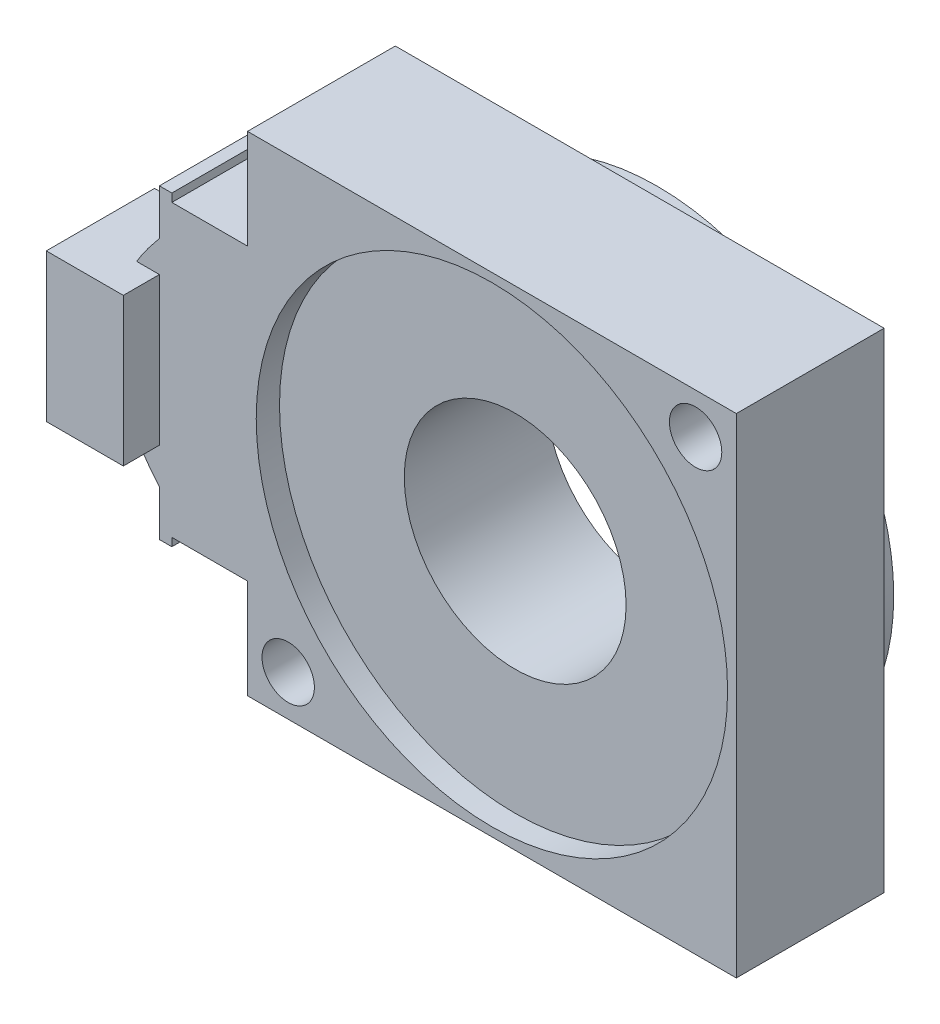
from build123d import *

# Parameters (mm, degrees)
BOSS_EXTRUDE1_DEPTH      = 12.7
SKETCH2_R                = 2.25
CUT_EXTRUDE1_DEPTH       = 12.7
BOSS_EXTRUDE4_DEPTH      = 12.7
SKETCH4_R                = 20.25
CUT_EXTRUDE2_DEPTH       = 2
SKETCH6_R                = 20.325
BOSS_EXTRUDE5_DEPTH      = 1.5
SKETCH5_R                = 9.53
CUT_EXTRUDE3_DEPTH       = 30
SKETCH8_W                = 6.62
SKETCH8_H                = 12.7
BOSS_EXTRUDE7_DEPTH      = 3.1
BOSS_EXTRUDE7_DEPTH_BACK = 6.2


with BuildPart() as part:
    # Sketch1 → Boss-Extrude1 (new body)
    with BuildSketch(Plane.XY):
        Polygon((0, 21), (21, 21), (21, -21), (-21, -21), (-21, 21), align=None)
    extrude(amount=BOSS_EXTRUDE1_DEPTH)

    # Sketch2 → Cut-Extrude1 (cut)
    with BuildSketch(Plane.XY):
        with Locations((17.500892834, 17.500892834)):
            Circle(SKETCH2_R)
        with Locations((-17.500892834, -17.500892834)):
            Circle(SKETCH2_R)
    extrude(amount=CUT_EXTRUDE1_DEPTH, mode=Mode.SUBTRACT)

    # Sketch3 → Boss-Extrude4 (add)
    with BuildSketch(Plane.XY.offset(12.7)):
        with BuildLine():
            Line((-21, -12.460892834), (-27.5, -12.460892834))
            Line((-27.5, -12.460892834), (-27.5, -13.160892834))
            Line((-27.5, -13.160892834), (-28.57, -13.160892834))
            Line((-28.57, -13.160892834), (-28.57, -9.240892834))
            add(Edge.make_bspline(
                [(-28.57, 9.240892834), (-36.45, 0), (-28.57, -9.240892834)],
                knots=[0, 0, 0, 1, 1, 1], degree=2))
            Line((-28.57, 9.240892834), (-28.57, 13.160892834))
            Line((-28.57, 13.160892834), (-27.5, 13.160892834))
            Line((-27.5, 13.160892834), (-27.5, 12.460892834))
            Line((-27.5, 12.460892834), (-21, 12.460892834))
            Line((-21, 12.460892834), (-21, -12.460892834))
        make_face()
    extrude(amount=-BOSS_EXTRUDE4_DEPTH)

    # Sketch4 → Cut-Extrude2 (cut)
    with BuildSketch(Plane.XY.offset(12.7)):
        Circle(SKETCH4_R)
    extrude(amount=-CUT_EXTRUDE2_DEPTH, mode=Mode.SUBTRACT)

    # Sketch6 → Boss-Extrude5 (add)
    with BuildSketch(Plane(origin=(0, 0, 0), x_dir=(-1, 0, 0), z_dir=(0, 0, -1))):
        Circle(SKETCH6_R)
    extrude(amount=BOSS_EXTRUDE5_DEPTH)

    # Sketch5 → Cut-Extrude3 (cut)
    with BuildSketch(Plane.XY.offset(10.7)):
        Circle(SKETCH5_R)
    extrude(amount=-CUT_EXTRUDE3_DEPTH, mode=Mode.SUBTRACT)

    # Sketch8 → Boss-Extrude7 (add, two sides)
    with BuildSketch(Plane.XY.offset(12.7)) as boss_extrude7_sk:
        with Locations((-31.88, 0.210892834)):
            Rectangle(SKETCH8_W, SKETCH8_H)
    extrude(amount=BOSS_EXTRUDE7_DEPTH)
    extrude(boss_extrude7_sk.sketch, amount=-BOSS_EXTRUDE7_DEPTH_BACK)


solid = part.part
